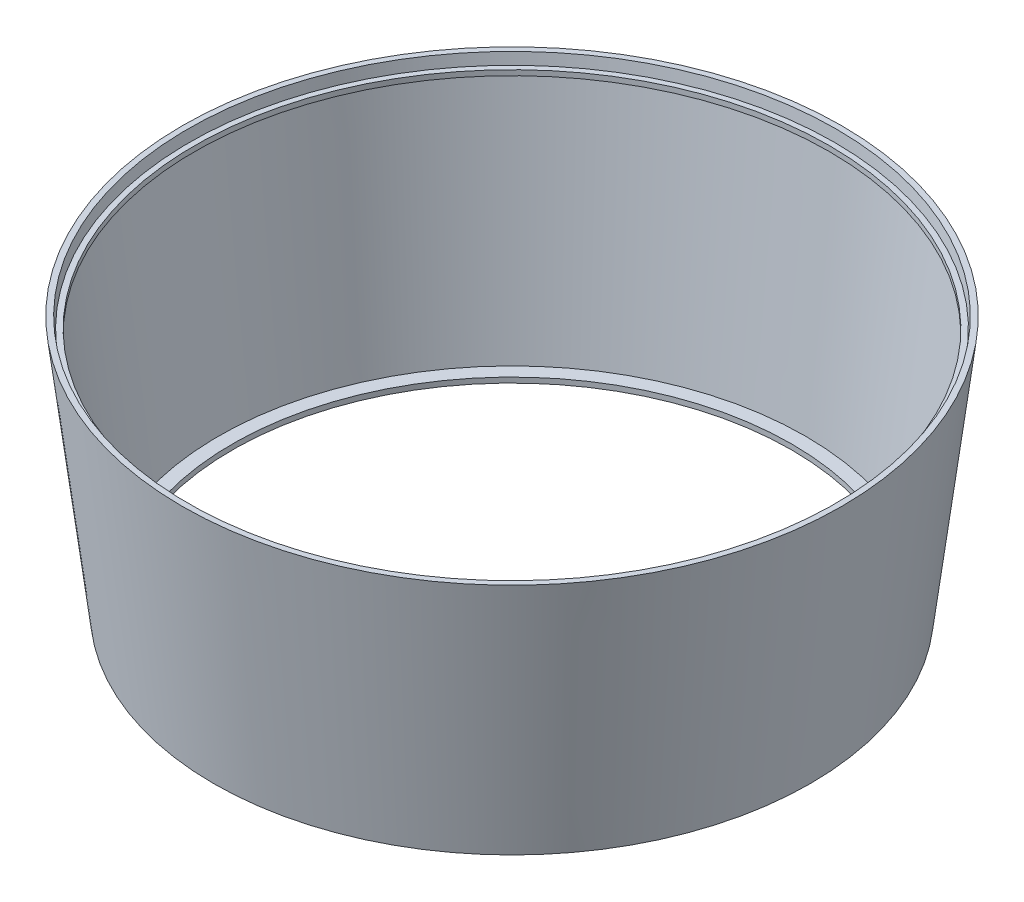
from build123d import *


with BuildPart() as part:
    # 草图1 → 旋转1 (revolve)
    with BuildSketch(Plane.XY):
        Polygon((0, 0), (50, 0), (134.45545498, 687.834483087), (119.45545498, 687.834483087), (115.799374678, 658.058098538), (101.359374678, 658.058098538), (101.359374678, 644.058098538), (114.080390825, 644.058098538), (36.718983853, 14), (0, 14), align=None)
    revolve(axis=Axis((-752, 0, 0), (0, 1, 0)))


solid = part.part
